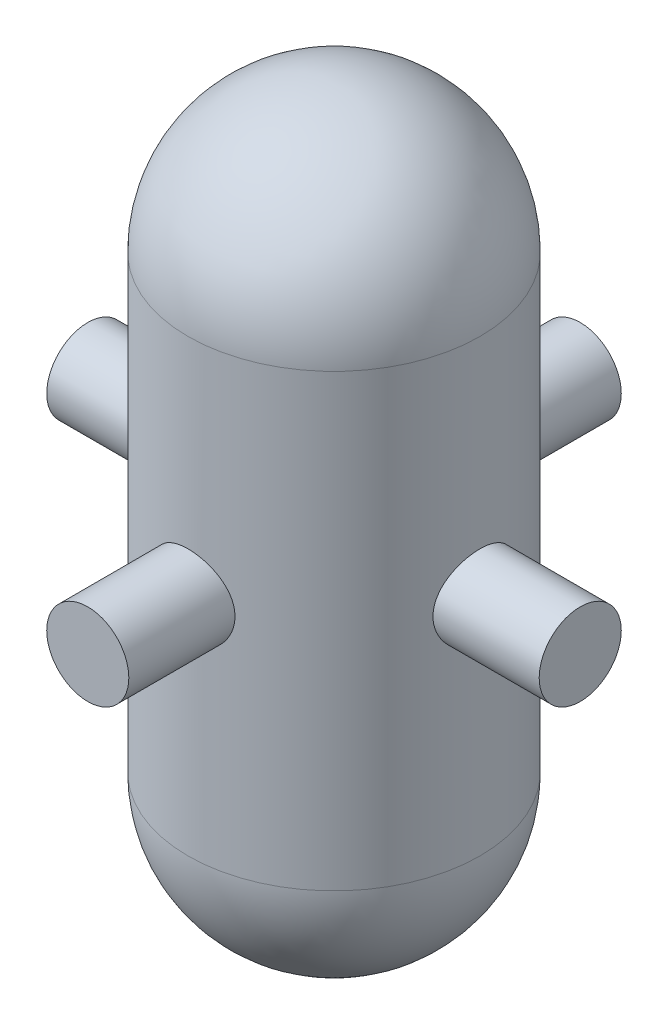
from build123d import *

# Parameters (mm, degrees)
SKETCH1_W           = 10
SKETCH1_H           = 113.33
SKETCH3_R           = 22.5
BOSS_EXTRUDE1_DEPTH = 135
SKETCH5_R           = 22.5
BOSS_EXTRUDE3_DEPTH = 135
SKETCH6_R           = 70
CUT_EXTRUDE1_DEPTH  = 25


with BuildPart() as part:
    # Sketch1 → Revolve1 (revolve)
    with BuildSketch(Plane.XY):
        Polygon((80, 113.33), (80, 123.33), (70, 123.33), (0, 123.33), (0, 113.33), (70, 113.33), align=None)
        with Locations((75, 56.665)):
            Rectangle(SKETCH1_W, SKETCH1_H)
        with BuildLine():
            Line((80, -123.33), (80, 0))
            Line((80, 0), (70, 0))
            Line((70, 0), (70, -123.33))
            ThreePointArc((70, -123.33), (49.497474683, -172.827474683), (0, -193.33))
            Line((0, -193.33), (0, -203.33))
            ThreePointArc((0, -203.33), (56.568542495, -179.898542495), (80, -123.33))
        make_face()
    revolve(axis=Axis((0, 203.33, 0), (0, -1, 0)))



with BuildPart() as body_2:
    # Sketch1_3 → Revolve2 (revolve)
    with BuildSketch(Plane.XY):
        with BuildLine():
            Line((0, 203.33), (0, 193.33))
            ThreePointArc((0, 193.33), (49.497474683, 172.827474683), (70, 123.33))
            Line((70, 123.33), (80, 123.33))
            ThreePointArc((80, 123.33), (56.568542495, 179.898542495), (0, 203.33))
        make_face()
    revolve(axis=Axis((0, 203.33, 0), (0, -1, 0)))


with BuildPart() as body_3:
    # Sketch3 → Boss-Extrude1 (new body, symmetric)
    with BuildSketch(Plane.XY):
        Circle(SKETCH3_R)
    extrude(amount=BOSS_EXTRUDE1_DEPTH, both=True)


with BuildPart() as part_1:
    add(part.part)

    add(body_3.part)  # Boss-Extrude3 merges body 3
    # Sketch5 → Boss-Extrude3 (add, symmetric)
    with BuildSketch(Plane(origin=(0, 0, 0), x_dir=(0, 0, -1), z_dir=(1, 0, 0))):
        Circle(SKETCH5_R)
    extrude(amount=BOSS_EXTRUDE3_DEPTH, both=True)

    # Sketch6 → Cut-Extrude1 (cut, symmetric)
    with BuildSketch(Plane(origin=(0, 0, 0), x_dir=(1, 0, 0), z_dir=(0, 1, 0))):
        Circle(SKETCH6_R)
    extrude(amount=CUT_EXTRUDE1_DEPTH, both=True, mode=Mode.SUBTRACT)


solid = Compound([body_2.part, part_1.part])
